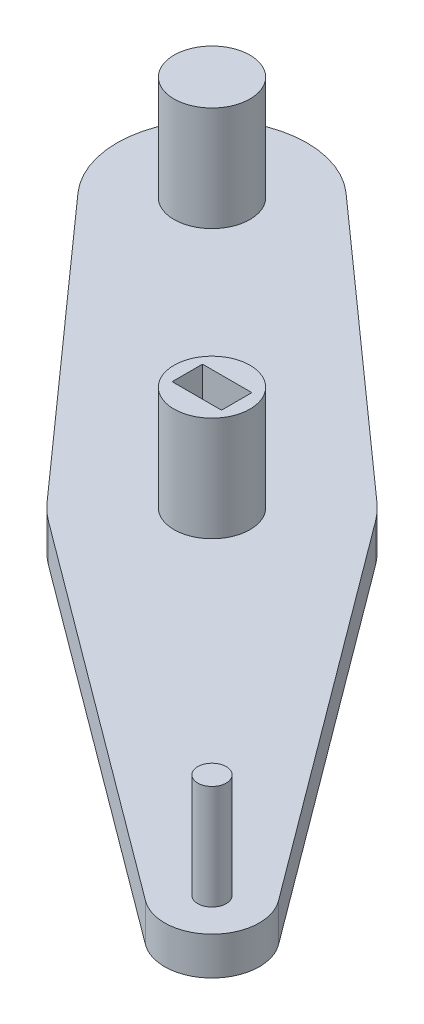
from build123d import *

# Parameters (mm, degrees)
BOSS_EXTRUDE1_DEPTH = 4
BOSS_EXTRUDE2_START = 4
SKETCH1_5_R         = 1.5
SKETCH1_5_R_2       = 4
BOSS_EXTRUDE2_DEPTH = 11
SKETCH4_W           = 5.2
SKETCH4_H           = 3.2
CUT_EXTRUDE1_DEPTH  = 111.595789101


with BuildPart() as part:
    # Sketch1 → Boss-Extrude1 (new body)
    with BuildSketch(Plane(origin=(0, 0, 0), x_dir=(1, 0, 0), z_dir=(0, 1, 0))):
        with BuildLine():
            ThreePointArc((-44.538463923, 34.672416737), (-43.657271509, 33.779661806), (-42.68973376, 32.981299644))
            Line((-42.68973376, 32.981299644), (-2.98146126, 3.486162839))
            ThreePointArc((-2.98146126, 3.486162839), (3.535533906, 3.964466094), (4.013837161, 10.48146126))
            Line((4.013837161, 10.48146126), (-25.481299644, 50.18973376))
            ThreePointArc((-25.481299644, 50.18973376), (-26.279661806, 51.157271509), (-27.172416737, 52.038463923))
            Line((-27.172416737, 52.038463923), (-56.986827931, 78.605565481))
            ThreePointArc((-56.986827931, 78.605565481), (-70.710678119, 78.210678119), (-71.105565481, 64.486827931))
            Line((-71.105565481, 64.486827931), (-44.538463923, 34.672416737))
        make_face()
    extrude(amount=BOSS_EXTRUDE1_DEPTH)

    # Sketch1_5 → Boss-Extrude2 (add)
    with BuildSketch(Plane(origin=(0, 0, 0), x_dir=(1, 0, 0), z_dir=(0, 1, 0)).offset(BOSS_EXTRUDE2_START)):
        with Locations((0, 7.5)):
            Circle(SKETCH1_5_R)
        with Locations((-35.355339059, 42.855339059)):
            Circle(SKETCH1_5_R_2)
        with Locations((-63.639610307, 71.139610307)):
            Circle(SKETCH1_5_R_2)
    extrude(amount=BOSS_EXTRUDE2_DEPTH)

    # Sketch4 → Cut-Extrude1 (cut, through all)
    with BuildSketch(Plane(origin=(0, 15, 0), x_dir=(1, 0, 0), z_dir=(0, 1, 0))):
        with Locations((-35.355339059, 42.855339059)):
            Rectangle(SKETCH4_W, SKETCH4_H)
    extrude(amount=-CUT_EXTRUDE1_DEPTH, mode=Mode.SUBTRACT)


solid = part.part
